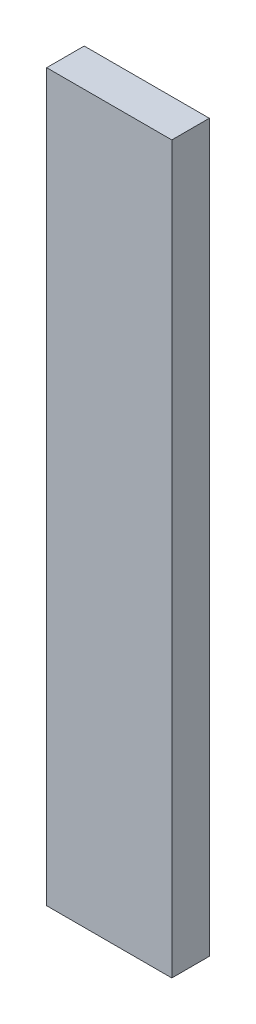
from build123d import *

# Parameters (mm, degrees)
ESQUISSE1_W        = 20
ESQUISSE1_H        = 116
BOSS_EXTRU_1_DEPTH = 6


with BuildPart() as part:
    # Esquisse1 → Boss.-Extru.1 (new body)
    with BuildSketch(Plane.XY):
        with Locations((0, 20)):
            Rectangle(ESQUISSE1_W, ESQUISSE1_H)
    extrude(amount=BOSS_EXTRU_1_DEPTH)


solid = part.part
